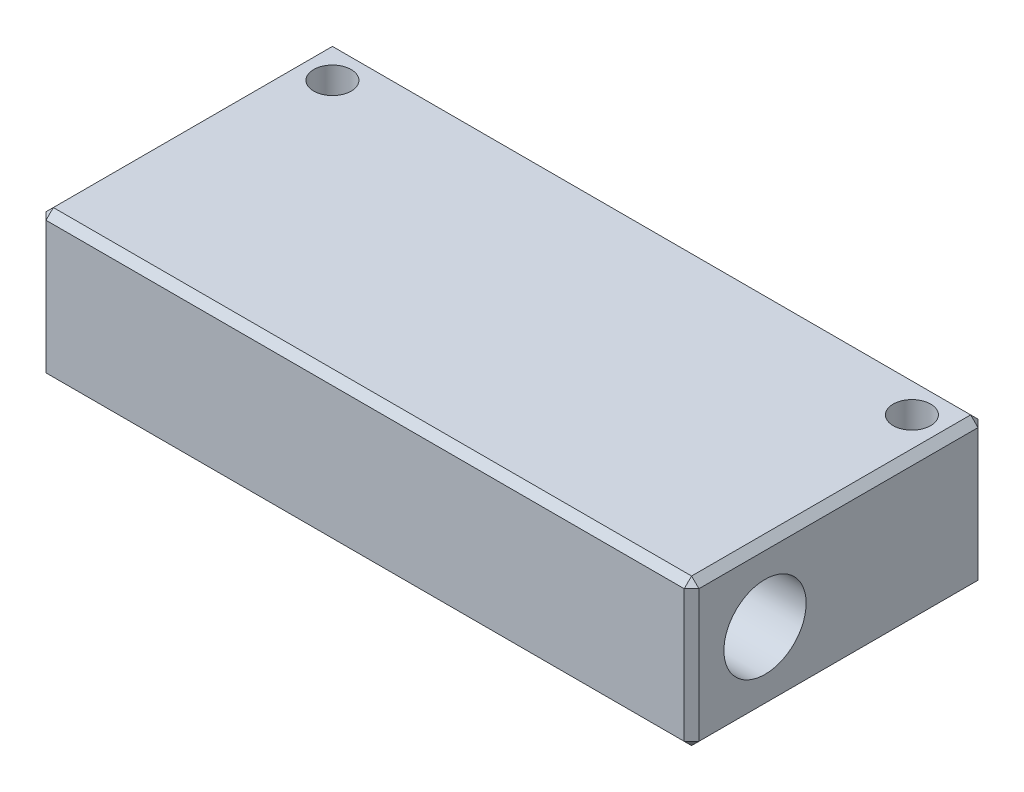
from build123d import *

# Parameters (mm, degrees)
SKETCH1_W               = 88.9
SKETCH1_H               = 40
BOSS_EXTRUDE1_DEPTH     = 20
SKETCH2_R               = 5
CUT_EXTRUDE1_DEPTH      = 89.9
SKETCH3_R               = 5.6
CUT_EXTRUDE2_DEPTH      = 10
SKETCH4_R               = 4
CUT_EXTRUDE3_DEPTH      = 10
F_1_4_20_TAPPED_HOLE1_D = 5.1054
CHAMFER1_SIZE           = 1


with BuildPart() as part:
    # Sketch1 → Boss-Extrude1 (new body)
    with BuildSketch(Plane(origin=(0, 0, 0), x_dir=(1, 0, 0), z_dir=(0, 1, 0))):
        Rectangle(SKETCH1_W, SKETCH1_H)
    extrude(amount=BOSS_EXTRUDE1_DEPTH)

    # Sketch2 → Cut-Extrude1 (cut, through all)
    with BuildSketch(Plane(origin=(44.45, 0, 0), x_dir=(0, 0, -1), z_dir=(1, 0, 0))):
        with Locations((-10, 10)):
            Circle(SKETCH2_R)
    extrude(amount=-CUT_EXTRUDE1_DEPTH, mode=Mode.SUBTRACT)

    # Sketch3 → Cut-Extrude2 (cut)
    with BuildSketch(Plane(origin=(44.45, 0, 0), x_dir=(0, 0, -1), z_dir=(1, 0, 0))):
        with Locations((-10, 10)):
            Circle(SKETCH3_R)
    cut_extrude2 = extrude(amount=-CUT_EXTRUDE2_DEPTH, mode=Mode.SUBTRACT)

    # Mirror1: Cut-Extrude2 across plane
    add(cut_extrude2.mirror(Plane(origin=(0, 0, 0), x_dir=(0, 0, 1), z_dir=(1, 0, 0))), mode=Mode.SUBTRACT)

    # Sketch4 → Cut-Extrude3 (cut)
    with BuildSketch(Plane(origin=(0, 0, -20), x_dir=(-1, 0, 0), z_dir=(0, 0, -1))):
        with Locations((-22.5, 10)):
            Circle(SKETCH4_R)
        with Locations((22.5, 10)):
            Circle(SKETCH4_R)
    extrude(amount=-CUT_EXTRUDE3_DEPTH, mode=Mode.SUBTRACT)

    # 1/4-20 Tapped Hole1 (through all)
    with Locations(Plane(origin=(0, 20, 0), x_dir=(1, 0, 0), z_dir=(0, 1, 0))):
        with Locations((39.45, 15), (-39.45, 15)):
            Hole(F_1_4_20_TAPPED_HOLE1_D / 2)

    # Chamfer1
    chamfer1_edges = [part.edges().sort_by_distance(p)[0] for p in [
        (-44.45, 20, 0),
        (0, 20, 20),
        (44.45, 20, 0),
        (0, 0, 20),
        (-44.45, 0, 0),
        (0, 0, -20),
        (44.45, 0, 0),
        (0, 20, -20),
        (44.45, 10, 20),
        (-44.45, 10, 20),
        (-44.45, 10, -20),
        (44.45, 10, -20),
    ]]
    chamfer(chamfer1_edges, length=CHAMFER1_SIZE)


solid = part.part
